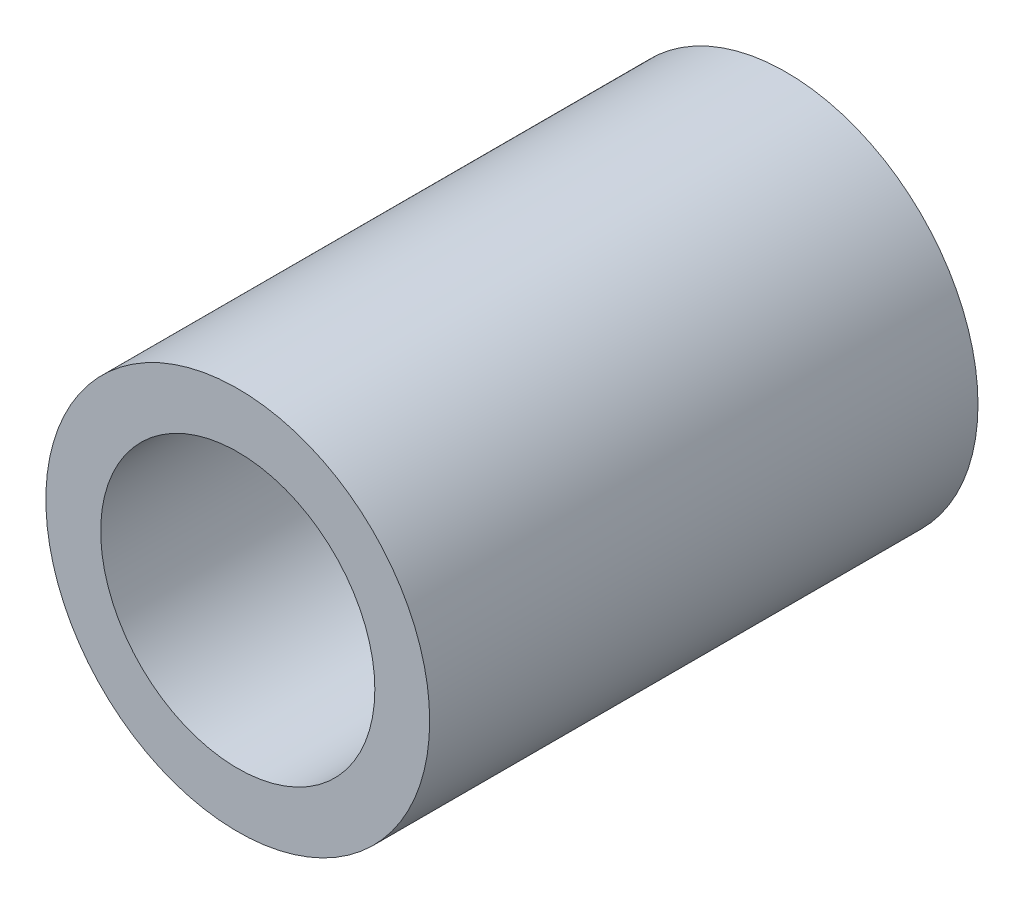
from build123d import *

# Parameters (mm, degrees)
SKETCH1_R           = 3.5
SKETCH1_R_2         = 2.5
BOSS_EXTRUDE1_DEPTH = 10


with BuildPart() as part:
    # Sketch1 → Boss-Extrude1 (new body)
    with BuildSketch(Plane.XY):
        Circle(SKETCH1_R)
        Circle(SKETCH1_R_2, mode=Mode.SUBTRACT)
    extrude(amount=BOSS_EXTRUDE1_DEPTH)


solid = part.part
